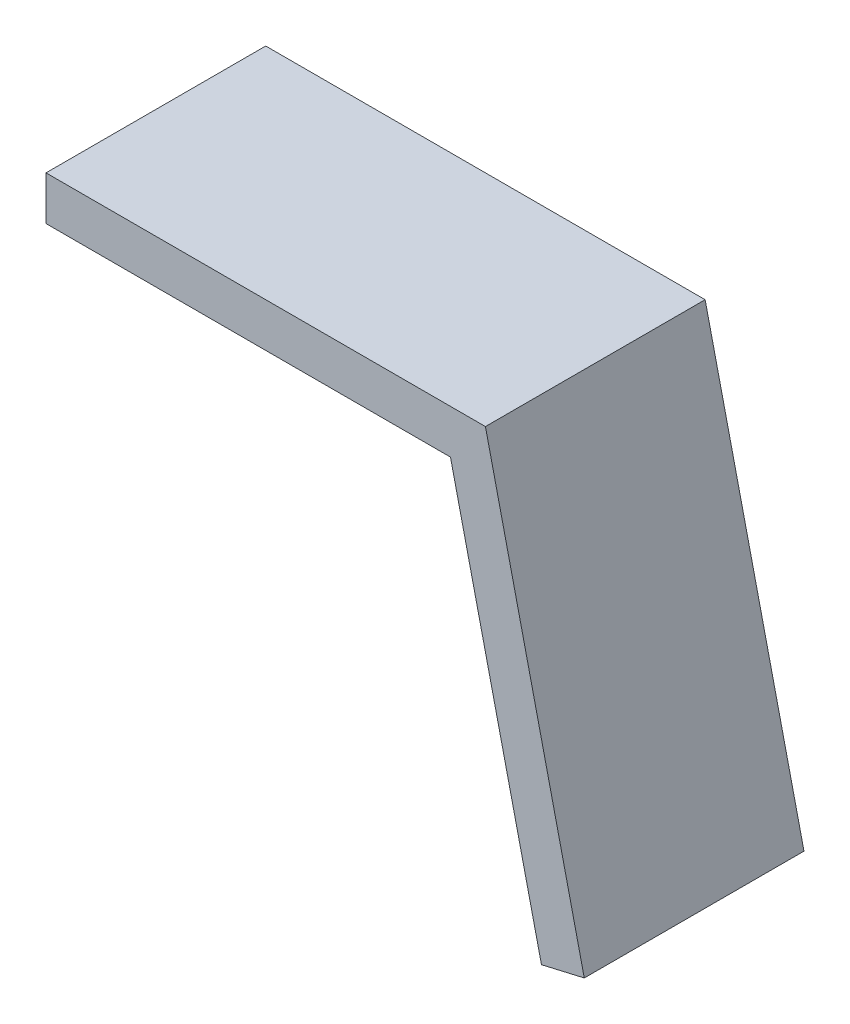
from build123d import *

# Parameters (mm, degrees)
BOSS_EXTRUDE1_DEPTH = 50


with BuildPart() as part:
    # Sketch1 → Boss-Extrude1 (new body)
    with BuildSketch(Plane.XY):
        Polygon((100, 0), (0, 0), (0, -10), (92.045640833, -10), (112.751404787, -99.686517022), (122.495105434, -97.437006479), align=None)
    extrude(amount=BOSS_EXTRUDE1_DEPTH)


solid = part.part
